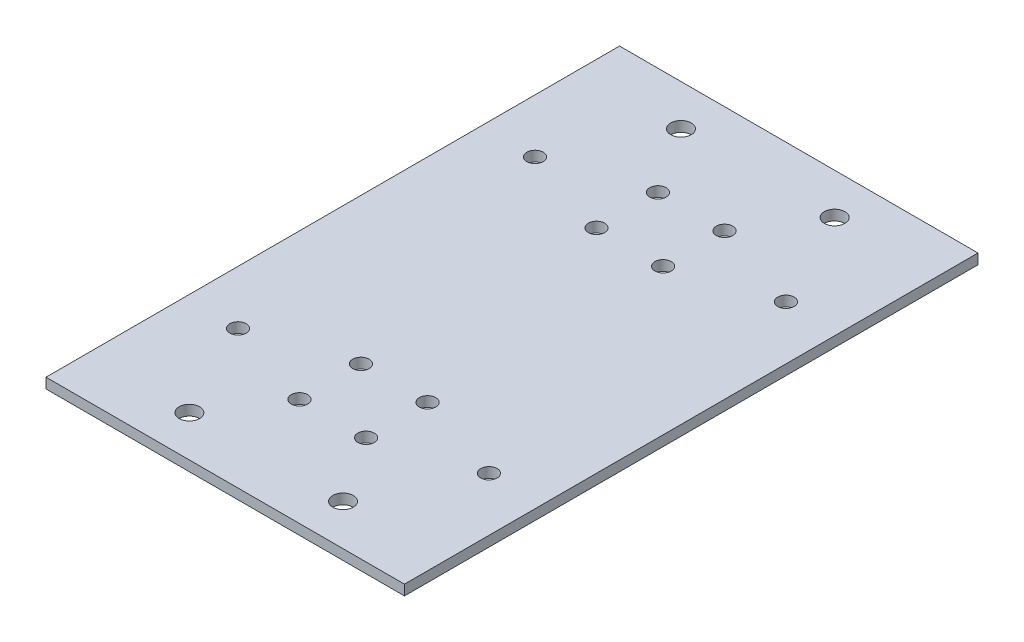
from build123d import *

# Parameters (mm, degrees)
SKETCH_2_W          = 70
SKETCH_2_H          = 112
SKETCH_2_R          = 1.6
EXTRUDE_1_DEPTH     = 2
SKETCH_3_R          = 2
CUT_EXTRUDE_1_DEPTH = 3


with BuildPart() as part:
    # 草圖2 → 填料-伸長1 (new body)
    with BuildSketch(Plane(origin=(0, 0, 0), x_dir=(1, 0, 0), z_dir=(0, 1, 0))):
        Rectangle(SKETCH_2_W, SKETCH_2_H)
        with Locations((-6.5, 35)):
            Circle(SKETCH_2_R, mode=Mode.SUBTRACT)
        with Locations((-6.5, -35)):
            Circle(SKETCH_2_R, mode=Mode.SUBTRACT)
        with Locations((-6.5, 23)):
            Circle(SKETCH_2_R, mode=Mode.SUBTRACT)
        with Locations((-6.5, -23)):
            Circle(SKETCH_2_R, mode=Mode.SUBTRACT)
        with Locations((6.5, -35)):
            Circle(SKETCH_2_R, mode=Mode.SUBTRACT)
        with Locations((6.5, -23)):
            Circle(SKETCH_2_R, mode=Mode.SUBTRACT)
        with Locations((6.5, 23)):
            Circle(SKETCH_2_R, mode=Mode.SUBTRACT)
        with Locations((6.5, 35)):
            Circle(SKETCH_2_R, mode=Mode.SUBTRACT)
        with Locations((-24.5, 29)):
            Circle(SKETCH_2_R, mode=Mode.SUBTRACT)
        with Locations((24.5, 29)):
            Circle(SKETCH_2_R, mode=Mode.SUBTRACT)
        with Locations((-24.5, -29)):
            Circle(SKETCH_2_R, mode=Mode.SUBTRACT)
        with Locations((24.5, -29)):
            Circle(SKETCH_2_R, mode=Mode.SUBTRACT)
    extrude(amount=EXTRUDE_1_DEPTH)

    # 草圖3 → 除料-伸長1 (cut, through all)
    with BuildSketch(Plane(origin=(0, 2, 0), x_dir=(1, 0, 0), z_dir=(0, 1, 0))):
        with Locations((-15, -48)):
            Circle(SKETCH_3_R)
        with Locations((-15, 48)):
            Circle(SKETCH_3_R)
        with Locations((15, -48)):
            Circle(SKETCH_3_R)
        with Locations((15, 48)):
            Circle(SKETCH_3_R)
    extrude(amount=-CUT_EXTRUDE_1_DEPTH, mode=Mode.SUBTRACT)


solid = part.part
